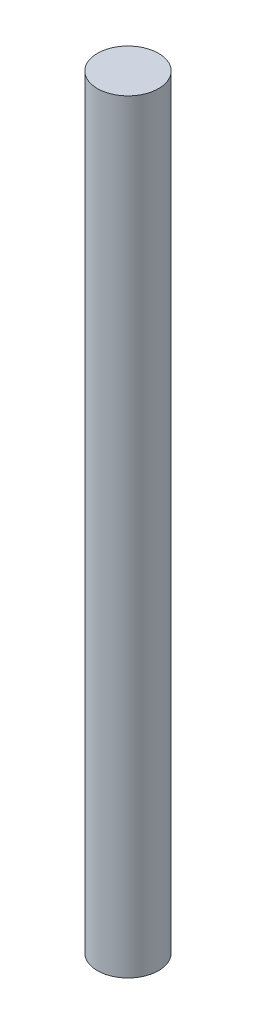
from build123d import *

# Parameters (mm, degrees)
SKETCH2_R           = 20
BOSS_EXTRUDE1_DEPTH = 500


with BuildPart() as part:
    # Sketch2 → Boss-Extrude1 (new body)
    with BuildSketch(Plane(origin=(0, 0, 0), x_dir=(1, 0, 0), z_dir=(0, 1, 0))):
        Circle(SKETCH2_R)
    extrude(amount=BOSS_EXTRUDE1_DEPTH)


solid = part.part
